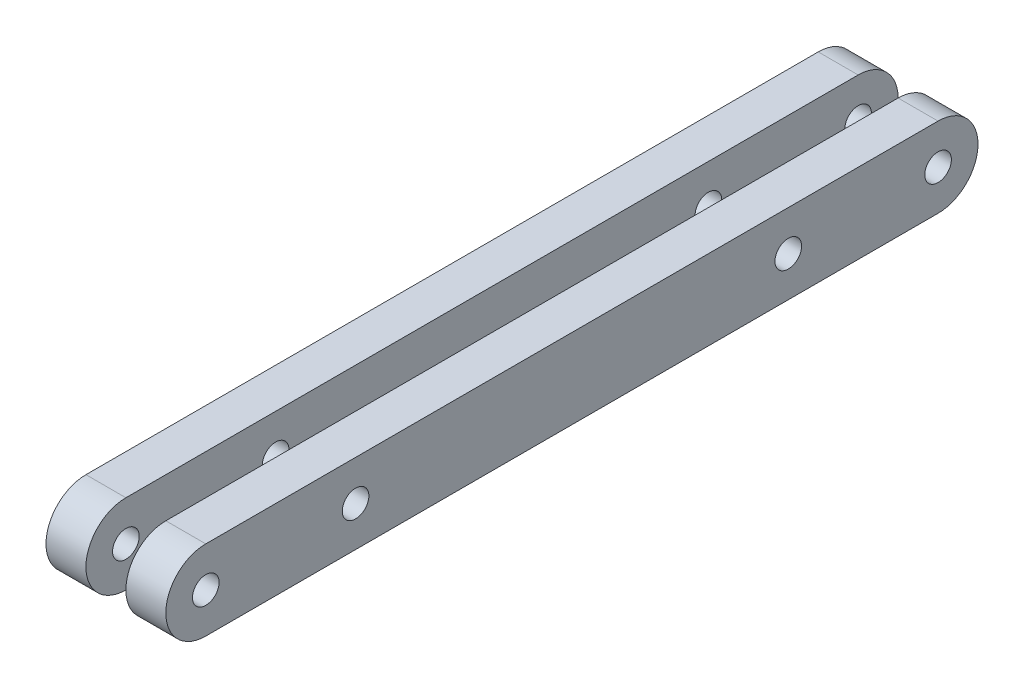
from build123d import *

# Parameters (mm, degrees)
BOSS_EXTRUDE1_DEPTH            = 6
CUT_EXTRUDE1_DEPTH             = 117.309930788
CUT_EXTRUDE1_DEPTH_BACK        = 117.309930788
SKETCH2_R                      = 2
SKETCH6_W                      = 2
SKETCH6_H                      = 18
F_4_0MM_DOWEL_HOLE1_AT_2_COUNT = 2
F_4_0MM_DOWEL_HOLE1_AT_2_PITCH = 65


with BuildPart() as part:
    # Sketch1 → Boss-Extrude1 (new body)
    with BuildSketch(Plane(origin=(3, 0, 0), x_dir=(0, 0, -1), z_dir=(1, 0, 0))):
        with BuildLine():
            Line((0, 6), (110, 6))
            ThreePointArc((110, 6), (116, 0), (110, -6))
            Line((110, -6), (0, -6))
            ThreePointArc((0, -6), (-6, 0), (0, 6))
        make_face()
    extrude(amount=BOSS_EXTRUDE1_DEPTH)

    # Sketch2 → Cut-Extrude1 (cut, two sides: drawn at the far end of the back side and taken through both)
    with BuildSketch(Plane(origin=(9, 0, 0), x_dir=(0, 0, -1), z_dir=(1, 0, 0)).offset(-CUT_EXTRUDE1_DEPTH_BACK)):
        Circle(SKETCH2_R)
        with Locations((110, 0)):
            Circle(SKETCH2_R)
    extrude(amount=CUT_EXTRUDE1_DEPTH + CUT_EXTRUDE1_DEPTH_BACK, mode=Mode.SUBTRACT)


with BuildPart() as body_2:
    # Mirror4: mirrored copy
    add(part.part.mirror(Plane(origin=(0, 0, 0), x_dir=(0, 0, 1), z_dir=(1, 0, 0))))


with BuildPart() as f_4_0mm_dowel_hole1_tool:
    # Sketch6 → Ø4.0mm Dowel Hole1 (revolve)
    with BuildSketch(Plane(origin=(9, 0, -87.5), x_dir=(0, 0, -1), z_dir=(0, 1, 0))):
        with Locations((1, 9)):
            Rectangle(SKETCH6_W, SKETCH6_H)
    f_4_0mm_dowel_hole1 = revolve(axis=Axis((15.35, 0, -87.5), (-1, 0, 0)))


with BuildPart() as part_1:
    add(part.part)

    # Ø4.0mm Dowel Hole1: cut by f_4_0mm_dowel_hole1_tool
    add(f_4_0mm_dowel_hole1_tool.part, mode=Mode.SUBTRACT)


with BuildPart() as body_2_1:
    add(body_2.part)

    # Ø4.0mm Dowel Hole1: cut by f_4_0mm_dowel_hole1_tool
    add(f_4_0mm_dowel_hole1_tool.part, mode=Mode.SUBTRACT)


with BuildPart() as f_4_0mm_dowel_hole1_at_2_tool:
    # Ø4.0mm Dowel Hole1 at 2: Ø4.0mm Dowel Hole1 ×2
    with Locations(*[(0, 0, i * F_4_0MM_DOWEL_HOLE1_AT_2_PITCH) for i in range(1, F_4_0MM_DOWEL_HOLE1_AT_2_COUNT)]):
        add(f_4_0mm_dowel_hole1)


with BuildPart() as part_2:
    add(part_1.part)

    # Ø4.0mm Dowel Hole1 at 2: cut by f_4_0mm_dowel_hole1_at_2_tool
    add(f_4_0mm_dowel_hole1_at_2_tool.part, mode=Mode.SUBTRACT)


with BuildPart() as body_2_2:
    add(body_2_1.part)

    # Ø4.0mm Dowel Hole1 at 2: cut by f_4_0mm_dowel_hole1_at_2_tool
    add(f_4_0mm_dowel_hole1_at_2_tool.part, mode=Mode.SUBTRACT)


solid = Compound([part_2.part, body_2_2.part])
